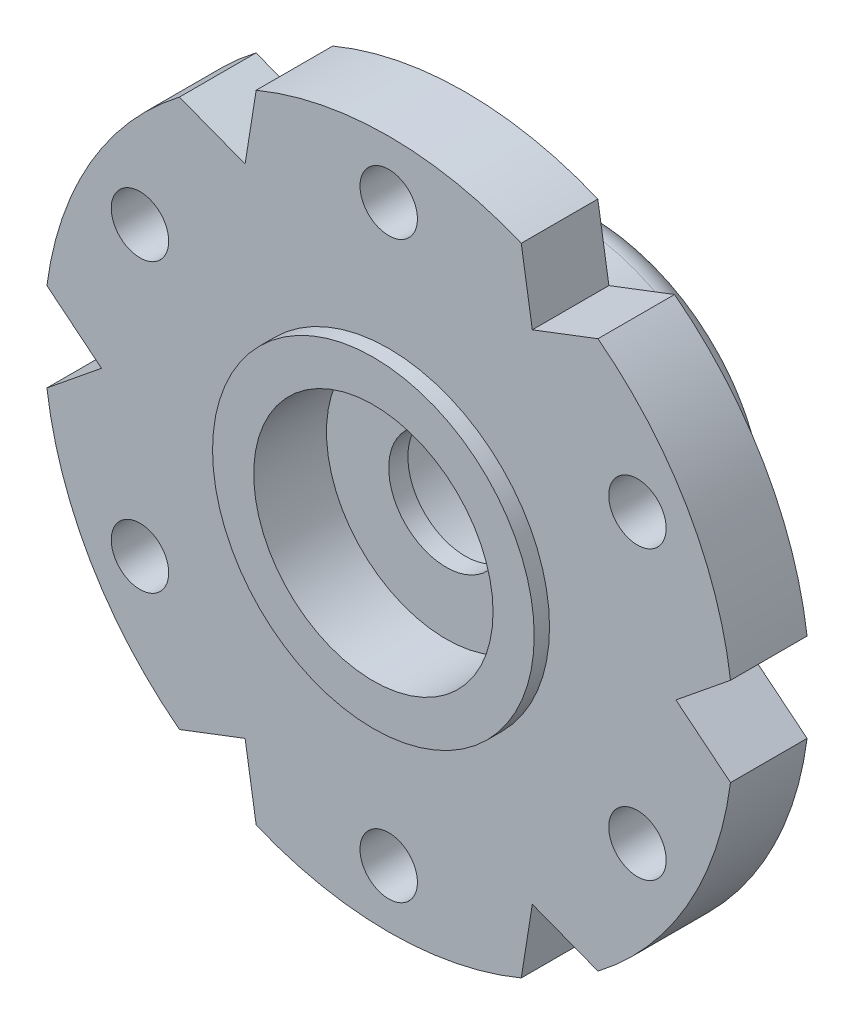
from build123d import *

# Parameters (mm, degrees)
SKETCH1_R           = 1.5
SKETCH1_R_2         = 0.75
BOSS_EXTRUDE1_DEPTH = 2
SKETCH2_R           = 4.75
SKETCH2_R_2         = 2.7
BOSS_EXTRUDE2_DEPTH = 3.5
SKETCH3_R           = 4.2
SKETCH3_R_2         = 3.125
BOSS_EXTRUDE3_DEPTH = 0.4
SKETCH4_R           = 3.125
CUT_EXTRUDE1_DEPTH  = 1.5
FILLET1_R           = 0.75
SKETCH5_OUTSIDE_W   = 39.274
SKETCH5_OUTSIDE_H   = 42.892
SKETCH5_OUTSIDE_R   = 9
CUT_EXTRUDE2_DEPTH  = 6.5


with BuildPart() as part:
    # Sketch1 → Boss-Extrude1 (new body)
    with BuildSketch(Plane.XY):
        with BuildLine():
            Line((-2.567552709, 13.90947904), (-3.75, 6.495190528))
            Line((-3.75, 6.495190528), (-10.762185848, 9.178305392))
            ThreePointArc((-10.762185848, 9.178305392), (-13.943009001, 8.05), (-13.329738557, 4.731173648))
            Line((-13.329738557, 4.731173648), (-7.5, 0))
            Line((-7.5, 0), (-13.329738557, -4.731173648))
            ThreePointArc((-13.329738557, -4.731173648), (-13.943009001, -8.05), (-10.762185848, -9.178305392))
            Line((-10.762185848, -9.178305392), (-3.75, -6.495190528))
            Line((-3.75, -6.495190528), (-2.567552709, -13.90947904))
            ThreePointArc((-2.567552709, -13.90947904), (0, -16.1), (2.567552709, -13.90947904))
            Line((2.567552709, -13.90947904), (3.75, -6.495190528))
            Line((3.75, -6.495190528), (10.762185848, -9.178305392))
            ThreePointArc((10.762185848, -9.178305392), (13.943009001, -8.05), (13.329738557, -4.731173648))
            Line((13.329738557, -4.731173648), (7.5, 0))
            Line((7.5, 0), (13.329738557, 4.731173648))
            ThreePointArc((13.329738557, 4.731173648), (13.943009001, 8.05), (10.762185848, 9.178305392))
            Line((10.762185848, 9.178305392), (3.75, 6.495190528))
            Line((3.75, 6.495190528), (2.567552709, 13.90947904))
            ThreePointArc((2.567552709, 13.90947904), (0, 16.1), (-2.567552709, 13.90947904))
        make_face()
        Circle(SKETCH1_R, mode=Mode.SUBTRACT)
        with Locations((0, 13.5)):
            Circle(SKETCH1_R_2, mode=Mode.SUBTRACT)
        with Locations((0, 10.5)):
            Circle(SKETCH1_R_2, mode=Mode.SUBTRACT)
        with Locations((0, 7.5)):
            Circle(SKETCH1_R_2, mode=Mode.SUBTRACT)
        with Locations((6.495190528, 3.75)):
            Circle(SKETCH1_R_2, mode=Mode.SUBTRACT)
        with Locations((9.09326674, 5.25)):
            Circle(SKETCH1_R_2, mode=Mode.SUBTRACT)
        with Locations((11.691342951, 6.75)):
            Circle(SKETCH1_R_2, mode=Mode.SUBTRACT)
        with Locations((6.495190528, -3.75)):
            Circle(SKETCH1_R_2, mode=Mode.SUBTRACT)
        with Locations((9.09326674, -5.25)):
            Circle(SKETCH1_R_2, mode=Mode.SUBTRACT)
        with Locations((11.691342951, -6.75)):
            Circle(SKETCH1_R_2, mode=Mode.SUBTRACT)
        with Locations((0, -7.5)):
            Circle(SKETCH1_R_2, mode=Mode.SUBTRACT)
        with Locations((0, -10.5)):
            Circle(SKETCH1_R_2, mode=Mode.SUBTRACT)
        with Locations((0, -13.5)):
            Circle(SKETCH1_R_2, mode=Mode.SUBTRACT)
        with Locations((-6.495190528, -3.75)):
            Circle(SKETCH1_R_2, mode=Mode.SUBTRACT)
        with Locations((-9.09326674, -5.25)):
            Circle(SKETCH1_R_2, mode=Mode.SUBTRACT)
        with Locations((-11.691342951, -6.75)):
            Circle(SKETCH1_R_2, mode=Mode.SUBTRACT)
        with Locations((-6.495190528, 3.75)):
            Circle(SKETCH1_R_2, mode=Mode.SUBTRACT)
        with Locations((-9.09326674, 5.25)):
            Circle(SKETCH1_R_2, mode=Mode.SUBTRACT)
        with Locations((-11.691342951, 6.75)):
            Circle(SKETCH1_R_2, mode=Mode.SUBTRACT)
    extrude(amount=BOSS_EXTRUDE1_DEPTH)

    # Sketch2 → Boss-Extrude2 (add)
    with BuildSketch(Plane(origin=(0, 0, 0), x_dir=(-1, 0, 0), z_dir=(0, 0, -1))):
        Circle(SKETCH2_R)
        Circle(SKETCH2_R_2, mode=Mode.SUBTRACT)
    extrude(amount=BOSS_EXTRUDE2_DEPTH)

    # Sketch3 → Boss-Extrude3 (add)
    with BuildSketch(Plane.XY.offset(2)):
        Circle(SKETCH3_R)
        Circle(SKETCH3_R_2, mode=Mode.SUBTRACT)
    extrude(amount=BOSS_EXTRUDE3_DEPTH)

    # Sketch4 → Cut-Extrude1 (cut)
    with BuildSketch(Plane.XY.offset(2)):
        Circle(SKETCH4_R)
    extrude(amount=-CUT_EXTRUDE1_DEPTH, mode=Mode.SUBTRACT)

    # Fillet1
    fillet1_edges = [part.edges().sort_by_distance(p)[0] for p in [
        (4.75, 0, 0),
        (4.75, 0, -3.5),
    ]]
    fillet(fillet1_edges, radius=FILLET1_R)

    # Sketch5 outside → Cut-Extrude2 (cut, through all)
    with BuildSketch(Plane.XY.offset(2)):
        Rectangle(SKETCH5_OUTSIDE_W, SKETCH5_OUTSIDE_H)
        Circle(SKETCH5_OUTSIDE_R, mode=Mode.SUBTRACT)
    extrude(amount=-CUT_EXTRUDE2_DEPTH, mode=Mode.SUBTRACT)


solid = part.part
